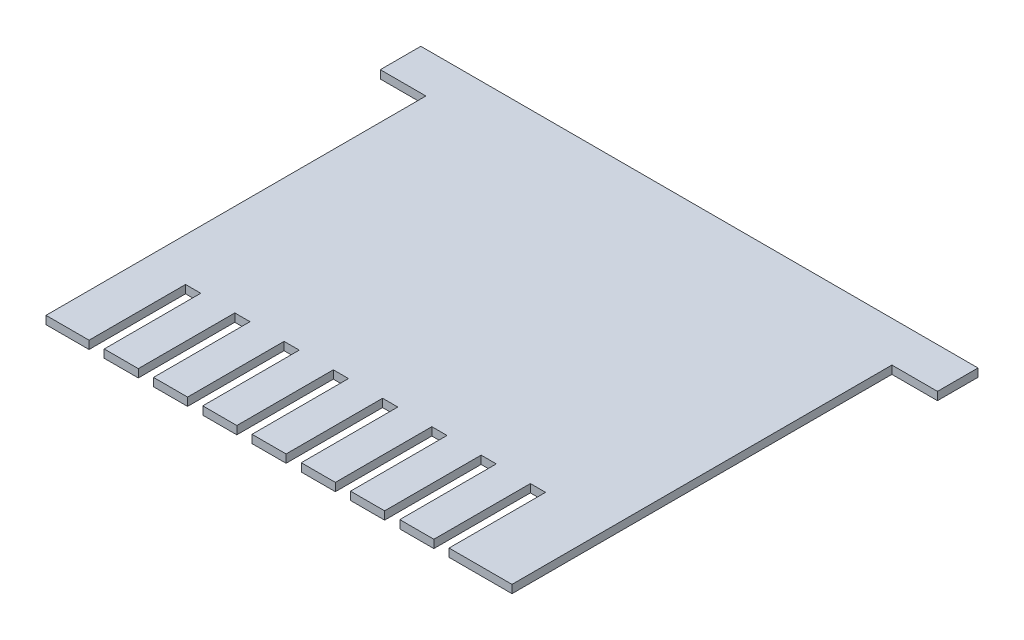
from build123d import *

# Parameters (mm, degrees)
BOSS_EXTRUDE1_DEPTH = 1.6


with BuildPart() as part:
    # Sketch1 → Boss-Extrude1 (new body)
    with BuildSketch(Plane(origin=(0, 0, 0), x_dir=(1, 0, 0), z_dir=(0, 1, 0))):
        Polygon((2.2, 75), (-6.8, 75), (-6.8, 83), (103.2, 83), (103.2, 75), (94.2, 75), (94.2, 0), (81.775, 0), (81.775, 19.05), (78.775, 19.05), (78.775, 0), (72.05, 0), (72.05, 19.05), (69.05, 19.05), (69.05, 0), (62.325, 0), (62.325, 19.05), (59.325, 19.05), (59.325, 0), (52.6, 0), (52.6, 19.05), (49.6, 19.05), (49.6, 0), (42.875, 0), (42.875, 19.05), (39.875, 19.05), (39.875, 0), (33.15, 0), (33.15, 19.05), (30.15, 19.05), (30.15, 0), (23.425, 0), (23.425, 19.05), (20.425, 19.05), (20.425, 0), (13.7, 0), (13.7, 19.05), (10.7, 19.05), (10.7, 0), (2.2, 0), align=None)
    extrude(amount=BOSS_EXTRUDE1_DEPTH)


solid = part.part
